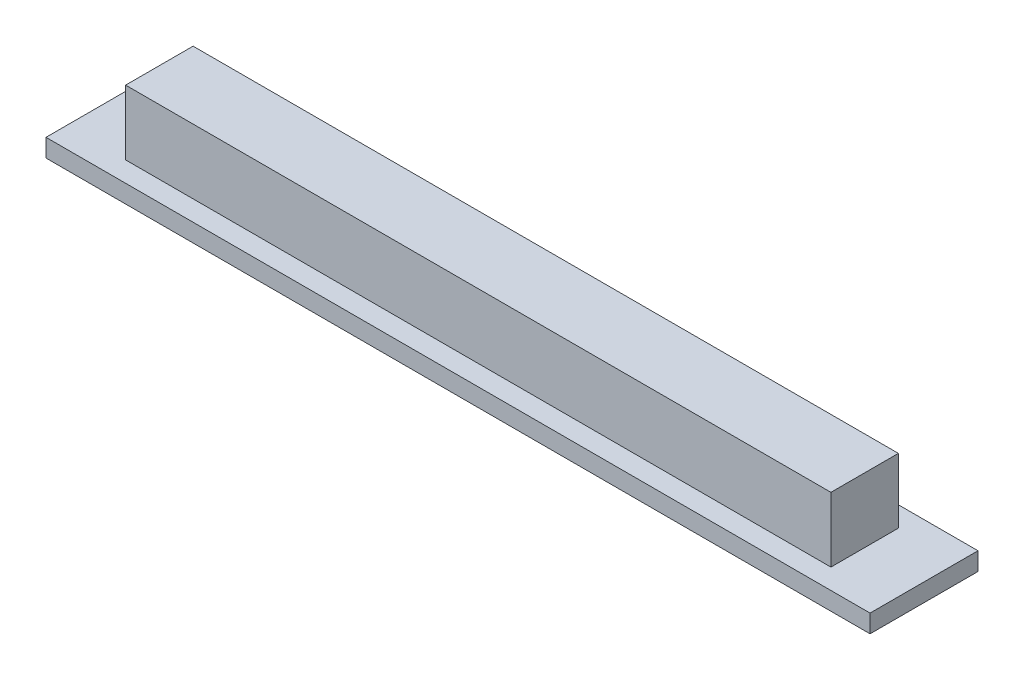
from build123d import *

# Parameters (mm, degrees)
SKETCH_1_W      = 45.8
SKETCH_1_H      = 6
EXTRUDE_1_DEPTH = 1
SKETCH_2_W      = 39.2
SKETCH_2_H      = 3.75
EXTRUDE_2_DEPTH = 3.6


with BuildPart() as part:
    # 草图1 → 凸台-拉伸1 (new body)
    with BuildSketch(Plane(origin=(0, 0, 0), x_dir=(1, 0, 0), z_dir=(0, 1, 0))):
        Rectangle(SKETCH_1_W, SKETCH_1_H)
    extrude(amount=EXTRUDE_1_DEPTH)

    # 草图2 → 凸台-拉伸2 (add)
    with BuildSketch(Plane(origin=(0, 1, 0), x_dir=(1, 0, 0), z_dir=(0, 1, 0))):
        Rectangle(SKETCH_2_W, SKETCH_2_H)
    extrude(amount=EXTRUDE_2_DEPTH)


solid = part.part
